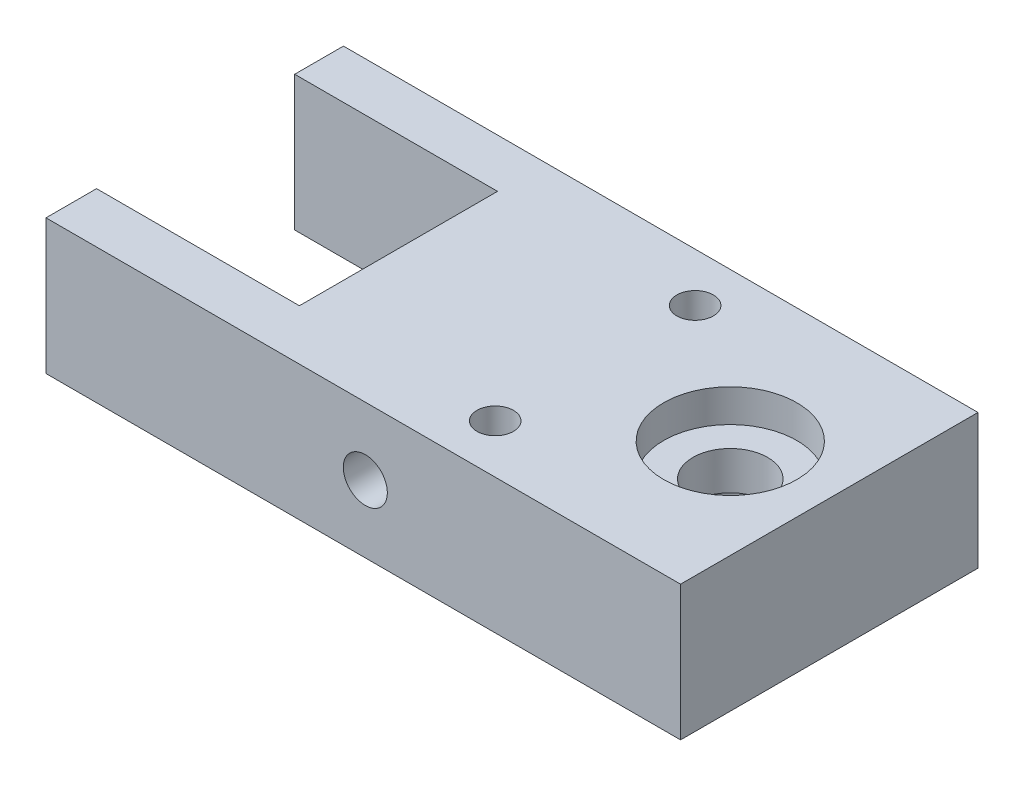
from build123d import *

# Parameters (mm, degrees)
SKETCH1_R              = 3.56
BOSS_EXTRUDE1_DEPTH    = 12.86
SKETCH2_R              = 2.085
CUT_EXTRUDE1_DEPTH     = 12.7
SKETCH3_R              = 6.35
CUT_EXTRUDE2_DEPTH     = 3.12
SKETCH4_R              = 5.57
CUT_EXTRUDE3_DEPTH     = 6.08
SKETCH5_R              = 1.74
CUT_EXTRUDE4_DEPTH     = 13.86
SKETCH6_R              = 1.735
CUT_EXTRUDE_8_32_DEPTH = 5
SKETCH7_R              = 2.1
CUT_EXTRUDE5_DEPTH     = 10


with BuildPart() as part:
    # Sketch1 → Boss-Extrude1 (new body)
    with BuildSketch(Plane(origin=(0, 0, 0), x_dir=(1, 0, 0), z_dir=(0, 1, 0))):
        Polygon((-31.72, 9.53), (-31.72, -9.36), (-51.06, -9.36), (-51.06, -14.18), (9.44, -14.18), (9.44, 14.18), (-51.06, 14.18), (-51.06, 9.53), align=None)
        Circle(SKETCH1_R, mode=Mode.SUBTRACT)
    extrude(amount=BOSS_EXTRUDE1_DEPTH)

    # Sketch2 → Cut-Extrude1 (cut)
    with BuildSketch(Plane.ZY.offset(31.72)):
        with Locations((-0.085, 6.43)):
            Circle(SKETCH2_R)
    extrude(amount=-CUT_EXTRUDE1_DEPTH, mode=Mode.SUBTRACT)

    # Sketch3 → Cut-Extrude2 (cut)
    with BuildSketch(Plane(origin=(0, 12.86, 0), x_dir=(-1, 0, 0), z_dir=(0, 1, 0))):
        Circle(SKETCH3_R)
    extrude(amount=-CUT_EXTRUDE2_DEPTH, mode=Mode.SUBTRACT)

    # Sketch4 → Cut-Extrude3 (cut)
    with BuildSketch(Plane.XZ):
        Circle(SKETCH4_R)
    extrude(amount=-CUT_EXTRUDE3_DEPTH, mode=Mode.SUBTRACT)

    # Sketch5 → Cut-Extrude4 (cut, through all)
    with BuildSketch(Plane.XZ):
        with Locations((-12.88, -9.53)):
            Circle(SKETCH5_R)
        with Locations((-12.88, 9.53)):
            Circle(SKETCH5_R)
    extrude(amount=-CUT_EXTRUDE4_DEPTH, mode=Mode.SUBTRACT)

    # Sketch6 → Cut-Extrude 8-32 (cut)
    with BuildSketch(Plane.XY.offset(14.18)):
        with Locations((-20.615, 6.43)):
            Circle(SKETCH6_R)
    extrude(amount=-CUT_EXTRUDE_8_32_DEPTH, mode=Mode.SUBTRACT)

    # Sketch7 → Cut-Extrude5 (cut)
    with BuildSketch(Plane.XY.offset(14.18)):
        with Locations((-20.615, 6.43)):
            Circle(SKETCH7_R)
    extrude(amount=-CUT_EXTRUDE5_DEPTH, mode=Mode.SUBTRACT)


solid = part.part
